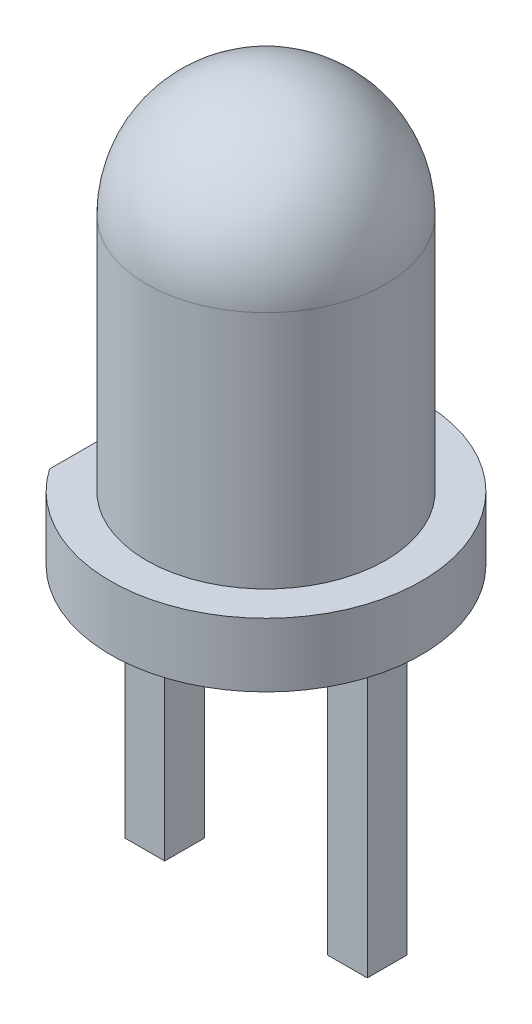
from build123d import *

# Parameters (mm, degrees)
ESQUISSE2_W             = 0.5
ESQUISSE2_H             = 0.5
BOSS_EXTRU_1_DEPTH      = 3.6
ESQUISSE3_W             = 1
ESQUISSE3_H             = 4
ENL_V_MAT_EXTRU_1_DEPTH = 6.3


with BuildPart() as part:
    # Esquisse1 → Révolution1 (revolve)
    with BuildSketch(Plane.XY):
        with BuildLine():
            Line((0, 0), (-1.95, 0))
            Line((-1.95, 0), (-1.95, 0.8))
            Line((-1.95, 0.8), (-1.5, 0.8))
            Line((-1.5, 0.8), (-1.5, 3.8))
            ThreePointArc((-1.5, 3.8), (-1.060660172, 4.860660172), (0, 5.3))
            Line((0, 5.3), (0, 0))
        make_face()
    revolve(axis=Axis((0, 5.3, 0), (0, -1, 0)))

    # Esquisse2 → Boss.-Extru.1 (add)
    with BuildSketch(Plane.XZ):
        with Locations((-1.27, 0)):
            Rectangle(ESQUISSE2_W, ESQUISSE2_H)
        with Locations((1.27, 0)):
            Rectangle(ESQUISSE2_W, ESQUISSE2_H)
    extrude(amount=BOSS_EXTRU_1_DEPTH)

    # Esquisse3 → Enlèv. mat.-Extru.1 (cut, through all)
    with BuildSketch(Plane.XZ):
        with Locations((-2.1, 0)):
            Rectangle(ESQUISSE3_W, ESQUISSE3_H)
    extrude(amount=-ENL_V_MAT_EXTRU_1_DEPTH, mode=Mode.SUBTRACT)


solid = part.part
